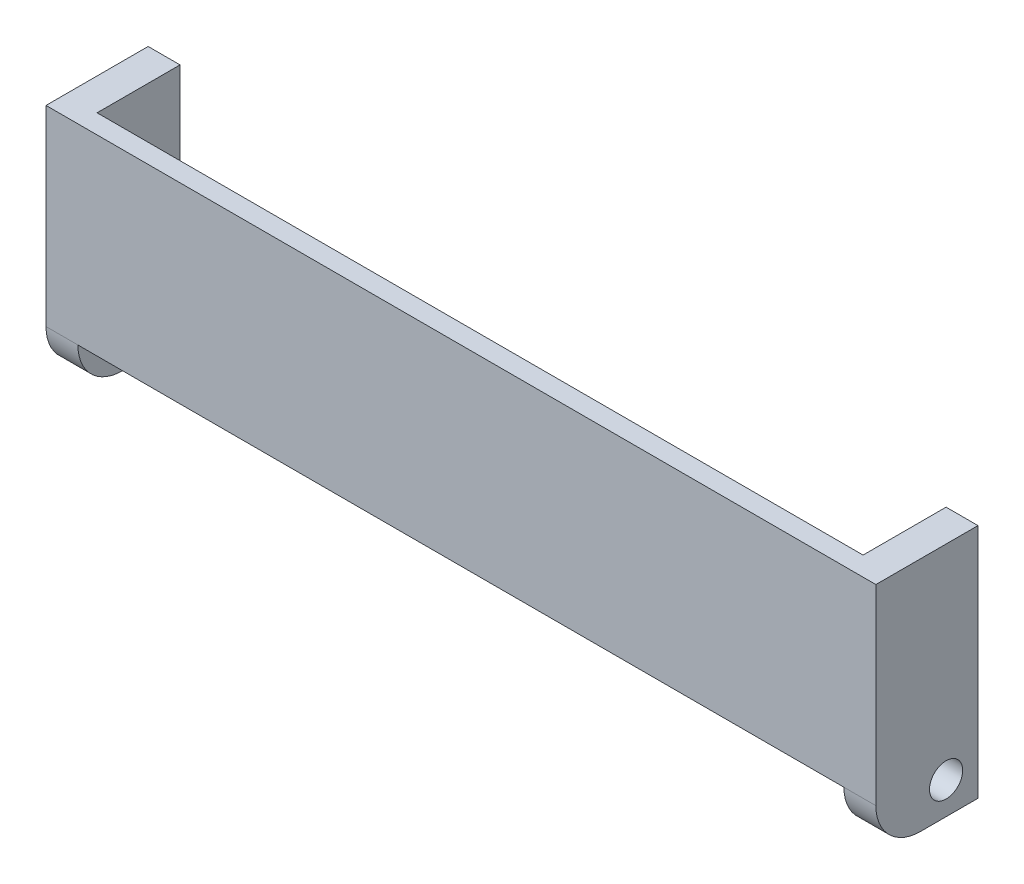
from build123d import *

# Parameters (mm, degrees)
ESQUISSE1_W             = 5
ESQUISSE1_H             = 40
BOSS_EXTRU_1_DEPTH      = 10
ESQUISSE2_R             = 2.6
ENL_V_MAT_EXTRU_1_DEPTH = 10
ESQUISSE3_W             = 5
ESQUISSE3_H             = 40
BOSS_EXTRU_2_DEPTH      = 6
CONG_1_R                = 7
ESQUISSE6_W             = 3
ESQUISSE6_H             = 33
BOSS_EXTRU_4_DEPTH      = 120
ESQUISSE8_R             = 2.6
BOSS_EXTRU_5_DEPTH      = 5
ESQUISSE9_W             = 130
ESQUISSE9_H             = 3
ENL_V_MAT_EXTRU_2_DEPTH = 20


with BuildPart() as part:
    # Esquisse1 → Boss.-Extru.1 (new body)
    with BuildSketch(Plane.XY):
        with Locations((2.5, -20)):
            Rectangle(ESQUISSE1_W, ESQUISSE1_H)
    extrude(amount=BOSS_EXTRU_1_DEPTH)

    # Esquisse2 → Enlèv. mat.-Extru.1 (cut)
    with BuildSketch(Plane(origin=(5, 0, 0), x_dir=(0, 0, -1), z_dir=(1, 0, 0))):
        with Locations((-5, -35)):
            Circle(ESQUISSE2_R)
    extrude(amount=-ENL_V_MAT_EXTRU_1_DEPTH, mode=Mode.SUBTRACT)

    # Esquisse3 → Boss.-Extru.2 (add)
    with BuildSketch(Plane.XY.offset(10)):
        with Locations((2.5, -20)):
            Rectangle(ESQUISSE3_W, ESQUISSE3_H)
    extrude(amount=BOSS_EXTRU_2_DEPTH)

    # Congé1
    cong_1_edges = [part.edges().sort_by_distance(p)[0] for p in [
        (2.5, -40, 16),
    ]]
    fillet(cong_1_edges, radius=CONG_1_R)

    # Esquisse6 → Boss.-Extru.4 (add)
    with BuildSketch(Plane.ZY):
        with Locations((14.5, -16.5)):
            Rectangle(ESQUISSE6_W, ESQUISSE6_H)
    extrude(amount=BOSS_EXTRU_4_DEPTH)

    # Esquisse8 → Boss.-Extru.5 (add)
    with BuildSketch(Plane.ZY.offset(120)):
        with BuildLine():
            Line((16, 0), (0, 0))
            Line((0, 0), (0, -40))
            Line((0, -40), (9, -40))
            ThreePointArc((9, -40), (13.949747468, -37.949747468), (16, -33))
            Line((16, -33), (16, 0))
        make_face()
        with Locations((5, -35)):
            Circle(ESQUISSE8_R, mode=Mode.SUBTRACT)
    extrude(amount=BOSS_EXTRU_5_DEPTH)

    # Esquisse9 → Enlèv. mat.-Extru.2 (cut)
    with BuildSketch(Plane.XY):
        with Locations((-60, -1.5)):
            Rectangle(ESQUISSE9_W, ESQUISSE9_H)
    extrude(amount=ENL_V_MAT_EXTRU_2_DEPTH, mode=Mode.SUBTRACT)


solid = part.part
